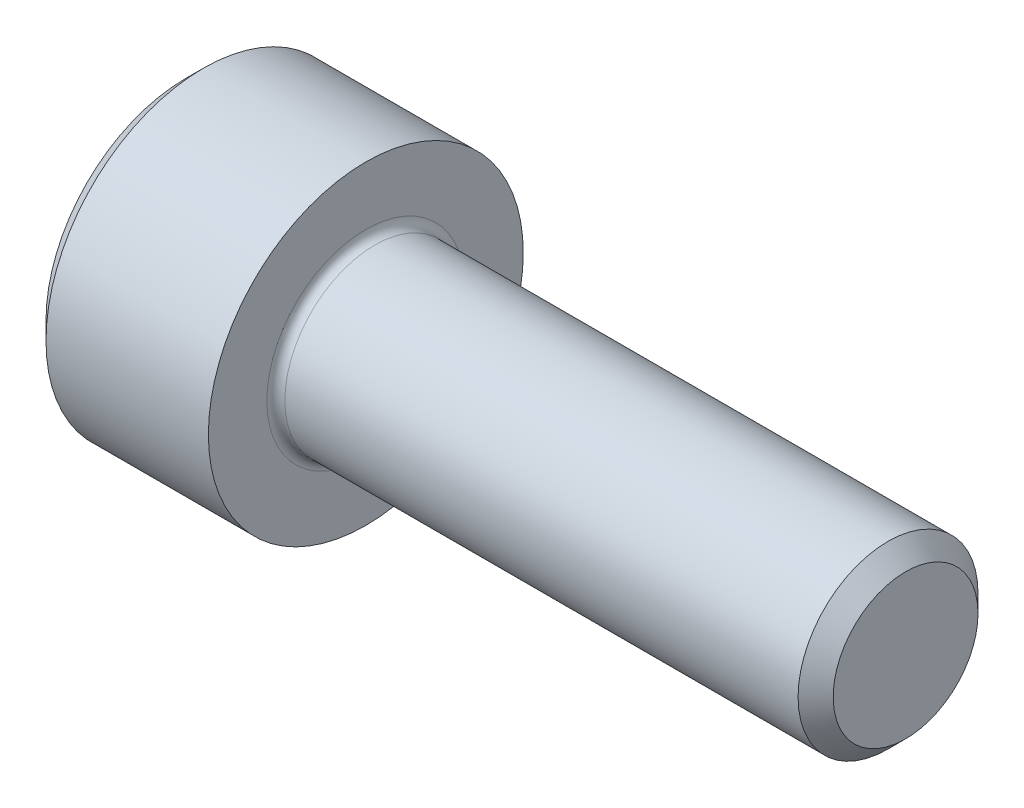
from build123d import *

# Parameters (mm, degrees)
SKETCH1_W           = 4
SKETCH1_H           = 3.5
SKETCH2_R           = 2
BOSS_EXTRUDE1_DEPTH = 12
CUT_EXTRUDE1_DEPTH  = 2
CHAMFER1_SIZE       = 0.39
FILLET1_R           = 0.2


with BuildPart() as part:
    # Sketch1 → Revolve1 (revolve)
    with BuildSketch(Plane(origin=(0, 0, 0), x_dir=(-1, 0, 0), z_dir=(0, 0, -1))):
        with Locations((-2, 1.75)):
            Rectangle(SKETCH1_W, SKETCH1_H)
    revolve(axis=Axis((4, 0, 0), (-1, 0, 0)))

    # Sketch2 → Boss-Extrude1 (add)
    with BuildSketch(Plane(origin=(4, 0, 0), x_dir=(0, 0, -1), z_dir=(1, 0, 0))):
        Circle(SKETCH2_R)
    extrude(amount=BOSS_EXTRUDE1_DEPTH)

    # Sketch3 → Cut-Extrude1 (cut)
    with BuildSketch(Plane.ZY):
        Polygon((1.5355, -0.886521338), (1.5355, 0.886521338), (0, 1.773042677), (-1.5355, 0.886521338), (-1.5355, -0.886521338), (0, -1.773042677), align=None)
    extrude(amount=-CUT_EXTRUDE1_DEPTH, mode=Mode.SUBTRACT)

    # Sketch4 → Cut-Revolve1 (revolve, cut)
    with BuildSketch(Plane.XY):
        Polygon((2, 1.5355), (2, 0), (2.886521338, 0), align=None)
    revolve(axis=Axis((2, 0, 0), (1, 0, 0)), mode=Mode.SUBTRACT)

    # Chamfer1
    chamfer1_edges = [part.edges().sort_by_distance(p)[0] for p in [
        (0, -3.5, 0),
        (16, 0, 2),
    ]]
    chamfer(chamfer1_edges, length=CHAMFER1_SIZE)

    # Fillet1
    fillet1_edges = [part.edges().sort_by_distance(p)[0] for p in [
        (4, 0, 2),
    ]]
    fillet(fillet1_edges, radius=FILLET1_R)


solid = part.part
